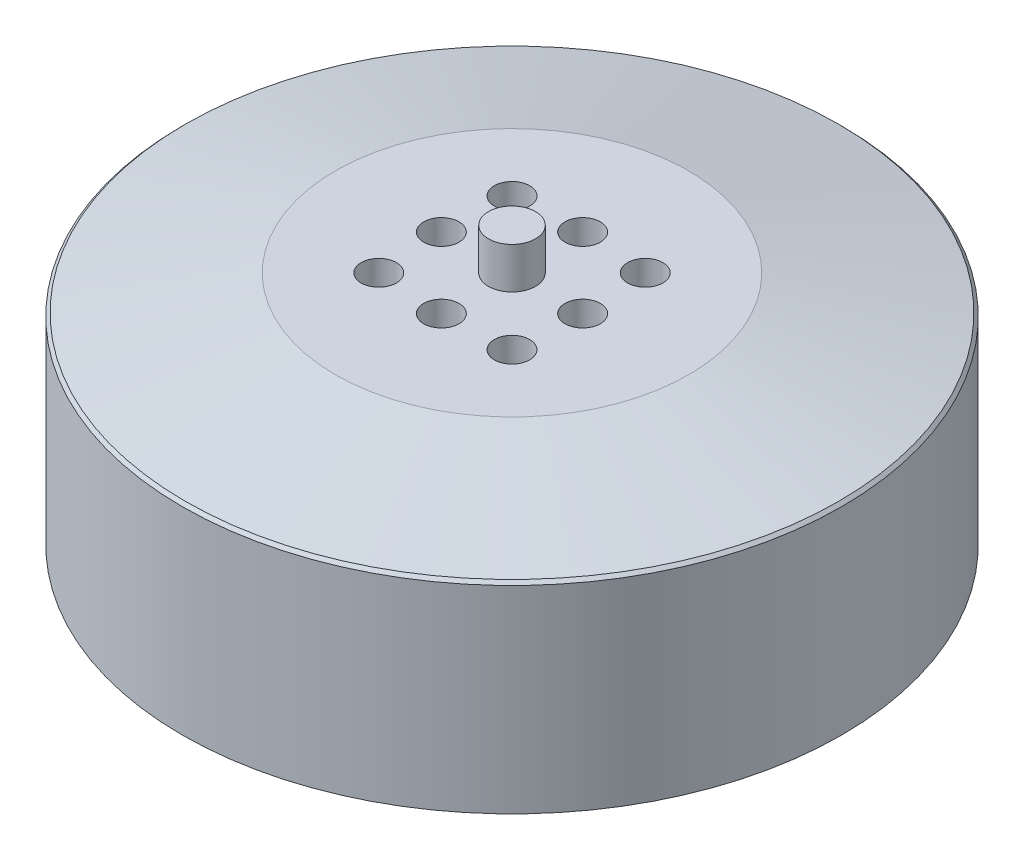
from build123d import *

# Parameters (mm, degrees)
ESQUISSE1_R             = 28
BOSS_EXTRU_1_DEPTH      = 20
CHANFREIN1_SIZE         = 0.2
CHANFREIN1_SIZE2        = 0.266833281
ESQUISSE3_R             = 2
BOSS_EXTRU_2_DEPTH      = 3.5
ESQUISSE4_R             = 1.5
ENL_V_MAT_EXTRU_1_DEPTH = 5
ESQUISSE5_R             = 1.5
ENL_V_MAT_EXTRU_2_DEPTH = 10


with BuildPart() as part:
    # Esquisse1 → Boss.-Extru.1 (new body)
    with BuildSketch(Plane(origin=(0, 0, 0), x_dir=(1, 0, 0), z_dir=(0, 1, 0))):
        with Locations(Location((0, 0, 0), (0, 0, 270))):
            Circle(ESQUISSE1_R)
    extrude(amount=BOSS_EXTRU_1_DEPTH)

    # Esquisse2 → Enlèvement de matière-Révolution1 (revolve, cut)
    with BuildSketch(Plane(origin=(0, 0, 0), x_dir=(0, 0, -1), z_dir=(1, 0, 0))):
        Polygon((-28, 20), (-28, 17), (-15, 20), align=None)
    revolve(axis=Axis((0, 20, 0), (0, -1, 0)), mode=Mode.SUBTRACT)

    # Chanfrein1
    chanfrein1_edges = [part.edges().sort_by_distance(p)[0] for p in [
        (0, 17, -28),
    ]]
    chanfrein1_side = [part.faces().sort_by_distance(p)[0] for p in [
        (0, 8.5, -28),
    ]]
    chamfer(chanfrein1_edges, length=CHANFREIN1_SIZE, length2=CHANFREIN1_SIZE2, reference=chanfrein1_side[0])

    # Esquisse3 → Boss.-Extru.2 (add)
    with BuildSketch(Plane(origin=(0, 20, 0), x_dir=(1, 0, 0), z_dir=(0, 1, 0))):
        with Locations(Location((0, 0, 0), (0, 0, 270))):
            Circle(ESQUISSE3_R)
    extrude(amount=BOSS_EXTRU_2_DEPTH)

    # Esquisse4 → Enlèv. mat.-Extru.1 (cut)
    with BuildSketch(Plane(origin=(0, 20, 0), x_dir=(1, 0, 0), z_dir=(0, 1, 0))):
        with Locations(Location((0, 6, 0), (0, 0, 270))):
            Circle(ESQUISSE4_R)
        with Locations(Location((6, 0, 0), (0, 0, 270))):
            Circle(ESQUISSE4_R)
        with Locations(Location((0, -6, 0), (0, 0, 270))):
            Circle(ESQUISSE4_R)
        with Locations(Location((-6, 0, 0), (0, 0, 270))):
            Circle(ESQUISSE4_R)
    extrude(amount=-ENL_V_MAT_EXTRU_1_DEPTH, mode=Mode.SUBTRACT)

    # Esquisse5 → Enlèv. mat.-Extru.2 (cut)
    with BuildSketch(Plane(origin=(0, 20, 0), x_dir=(1, 0, 0), z_dir=(0, 1, 0))):
        with Locations(Location((-5.656854249, 5.656854249, 0), (0, 0, 270))):
            Circle(ESQUISSE5_R)
        with Locations(Location((5.656854249, 5.656854249, 0), (0, 0, 270))):
            Circle(ESQUISSE5_R)
        with Locations(Location((5.656854249, -5.656854249, 0), (0, 0, 270))):
            Circle(ESQUISSE5_R)
        with Locations(Location((-5.656854249, -5.656854249, 0), (0, 0, 270))):
            Circle(ESQUISSE5_R)
    extrude(amount=-ENL_V_MAT_EXTRU_2_DEPTH, mode=Mode.SUBTRACT)


solid = part.part
